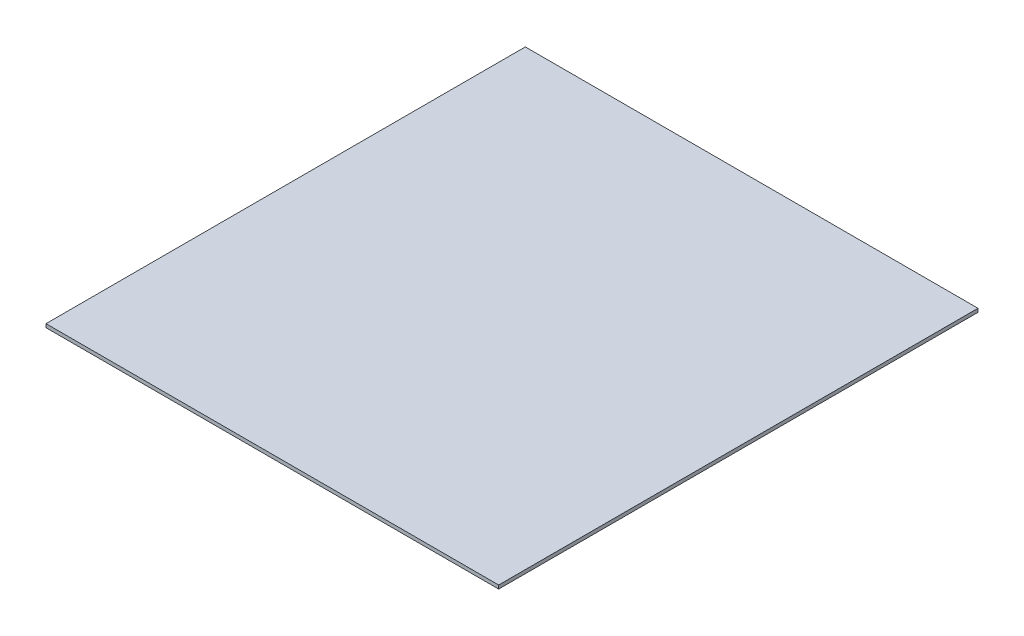
from build123d import *

# Parameters (mm, degrees)
SKETCH1_W           = 510
SKETCH1_H           = 540
BOSS_EXTRUDE1_DEPTH = 4


with BuildPart() as part:
    # Sketch1 → Boss-Extrude1 (new body)
    with BuildSketch(Plane(origin=(0, 0, 0), x_dir=(1, 0, 0), z_dir=(0, 1, 0))):
        Rectangle(SKETCH1_W, SKETCH1_H)
    extrude(amount=BOSS_EXTRUDE1_DEPTH)


solid = part.part
